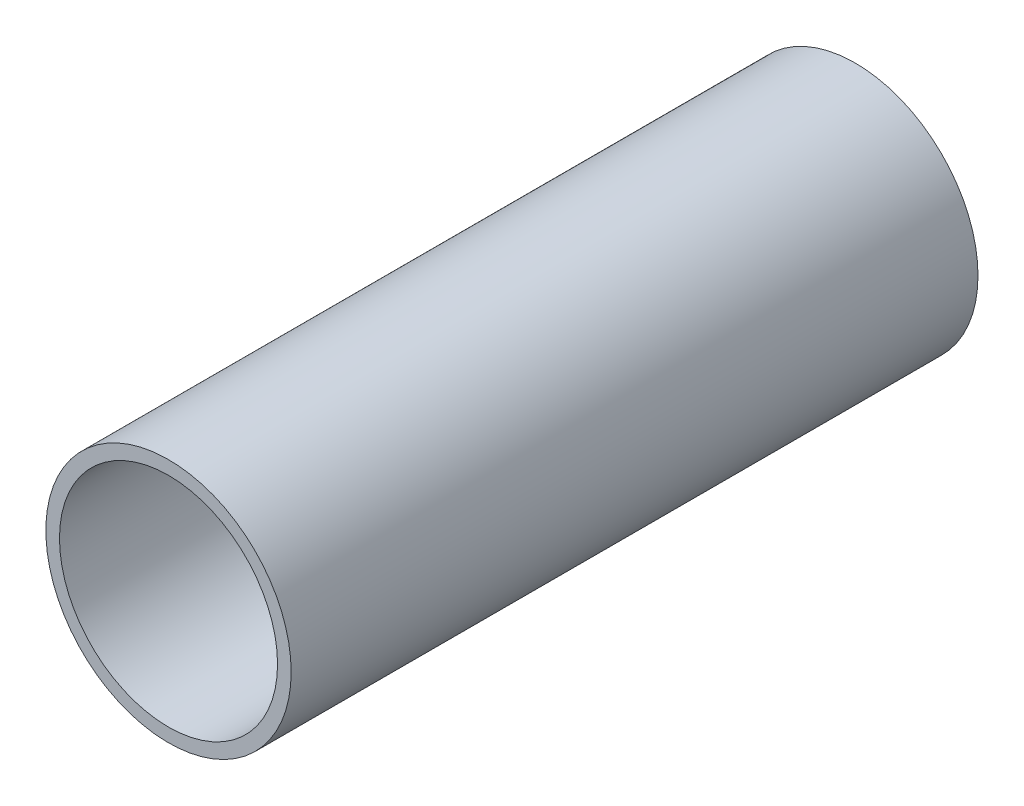
from build123d import *

# Parameters (mm, degrees)
SKETCH1_R           = 28.575
SKETCH1_R_2         = 25.4
BOSS_EXTRUDE1_DEPTH = 80


with BuildPart() as part:
    # Sketch1 → Boss-Extrude1 (new body, symmetric)
    with BuildSketch(Plane.XY):
        Circle(SKETCH1_R)
        Circle(SKETCH1_R_2, mode=Mode.SUBTRACT)
    extrude(amount=BOSS_EXTRUDE1_DEPTH, both=True)


solid = part.part
